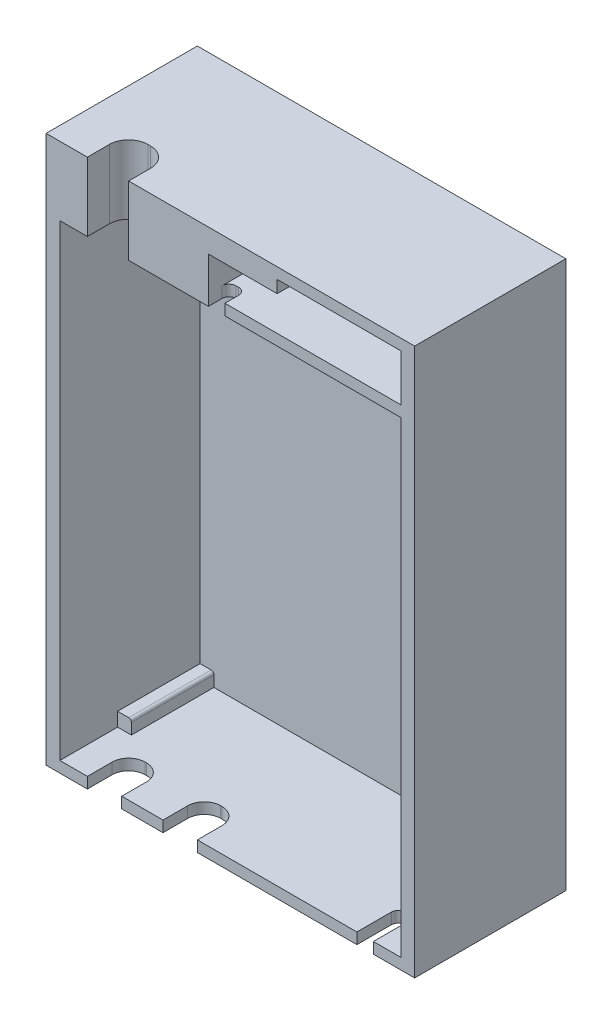
from build123d import *

# Parameters (mm, degrees)
SKETCH_3_W          = 26.8
SKETCH_3_H          = 39.8
EXTRUDE_3_DEPTH     = 11
SKETCH_3_3_W        = 24.8
SKETCH_3_3_H        = 34
SKETCH_3_3_W_2      = 9
SKETCH_3_3_H_2      = 3.4
CUT_EXTRUDE_1_DEPTH = 10.2
SKETCH_3_4_W        = 3
SKETCH_3_4_H        = 5
CUT_EXTRUDE_2_DEPTH = 3
SKETCH_3_5_W        = 2.5
SKETCH_3_5_H        = 0.8
CUT_EXTRUDE_3_DEPTH = 3
SKETCH_3_6_W        = 1.2
SKETCH_3_6_H        = 0.8
CUT_EXTRUDE_4_DEPTH = 3
SKETCH_3_7_W        = 1.2
SKETCH_3_7_H        = 0.8
CUT_EXTRUDE_5_DEPTH = 1.5
EXTRUDE_4_DEPTH     = 6
FILLET_1_R          = 1.4
FILLET_2_R          = 1.2
FILLET_3_R          = 0.5


with BuildPart() as part:
    # Sketch 3 → Extrude 3 (new body)
    with BuildSketch(Plane.XY):
        with Locations((13.4, 19.9)):
            Rectangle(SKETCH_3_W, SKETCH_3_H)
    extrude(amount=-EXTRUDE_3_DEPTH)

    # Sketch 3_3 → Cut-Extrude 1 (cut)
    with BuildSketch(Plane.XY):
        with Locations((13.4, 17.8)):
            Rectangle(SKETCH_3_3_W, SKETCH_3_3_H)
        with Locations((21.3, 37.3)):
            Rectangle(SKETCH_3_3_W_2, SKETCH_3_3_H_2)
        Polygon((11.8, 38.1), (11.8, 35.6), (13, 35.6), (16.8, 35.6), (16.8, 38.1), align=None)
    extrude(amount=-CUT_EXTRUDE_1_DEPTH, mode=Mode.SUBTRACT)

    # Sketch 3_4 → Cut-Extrude 2 (cut)
    with BuildSketch(Plane.XY):
        with Locations((4.5, 37.3)):
            Rectangle(SKETCH_3_4_W, SKETCH_3_4_H)
    extrude(amount=-CUT_EXTRUDE_2_DEPTH, mode=Mode.SUBTRACT)

    # Sketch 3_5 → Cut-Extrude 3 (cut)
    with BuildSketch(Plane.XY):
        with Locations((4.25, 0.4)):
            Rectangle(SKETCH_3_5_W, SKETCH_3_5_H)
        with Locations((9.75, 0.4)):
            Rectangle(SKETCH_3_5_W, SKETCH_3_5_H)
    extrude(amount=-CUT_EXTRUDE_3_DEPTH, mode=Mode.SUBTRACT)

    # Sketch 3_6 → Cut-Extrude 4 (cut)
    with BuildSketch(Plane.XY):
        with Locations((23.2, 0.4)):
            Rectangle(SKETCH_3_6_W, SKETCH_3_6_H)
    extrude(amount=-CUT_EXTRUDE_4_DEPTH, mode=Mode.SUBTRACT)

    # Sketch 3_7 → Cut-Extrude 5 (cut)
    with BuildSketch(Plane.XY):
        with Locations((12.4, 35.2)):
            Rectangle(SKETCH_3_7_W, SKETCH_3_7_H)
    extrude(amount=-CUT_EXTRUDE_5_DEPTH, mode=Mode.SUBTRACT)

    # Sketch 4 → Extrude 4 (add)
    with BuildSketch(Plane.XY.offset(-10.2)):
        with BuildLine():
            Line((10.4, 34.8), (16.4, 34.8))
            Line((16.4, 34.8), (16.4, 33.415875518))
            ThreePointArc((16.4, 33.415875518), (16.341421356, 33.274454162), (16.2, 33.215875518))
            Line((16.2, 33.215875518), (10.6, 33.215875518))
            ThreePointArc((10.6, 33.215875518), (10.458578644, 33.274454162), (10.4, 33.415875518))
            Line((10.4, 33.415875518), (10.4, 34.8))
        make_face()
        with BuildLine():
            Line((1, 0.8), (2, 0.8))
            Line((2, 0.8), (2, 1.6))
            ThreePointArc((2, 1.6), (1.941421356, 1.741421356), (1.8, 1.8))
            Line((1.8, 1.8), (1, 1.8))
            Line((1, 1.8), (1, 0.8))
        make_face()
        with BuildLine():
            Line((25.8, 0.8), (24.8, 0.8))
            Line((24.8, 0.8), (24.8, 1.6))
            ThreePointArc((24.8, 1.6), (24.858578644, 1.741421356), (25, 1.8))
            Line((25, 1.8), (25.8, 1.8))
            Line((25.8, 1.8), (25.8, 0.8))
        make_face()
    extrude(amount=EXTRUDE_4_DEPTH)

    # Fillet 1
    fillet_1_edges = [part.edges().sort_by_distance(p)[0] for p in [
        (3, 37.3, -3),
        (6, 37.3, -3),
    ]]
    fillet(fillet_1_edges, radius=FILLET_1_R)

    # Fillet 2
    fillet_2_edges = [part.edges().sort_by_distance(p)[0] for p in [
        (3, 0.4, -3),
        (5.5, 0.4, -3),
        (8.5, 0.4, -3),
        (11, 0.4, -3),
    ]]
    fillet(fillet_2_edges, radius=FILLET_2_R)

    # Fillet 3
    fillet_3_edges = [part.edges().sort_by_distance(p)[0] for p in [
        (23.8, 0.4, -3),
        (11.8, 35.2, -1.5),
        (13, 35.2, -1.5),
        (22.6, 0.4, -3),
    ]]
    fillet(fillet_3_edges, radius=FILLET_3_R)


solid = part.part
